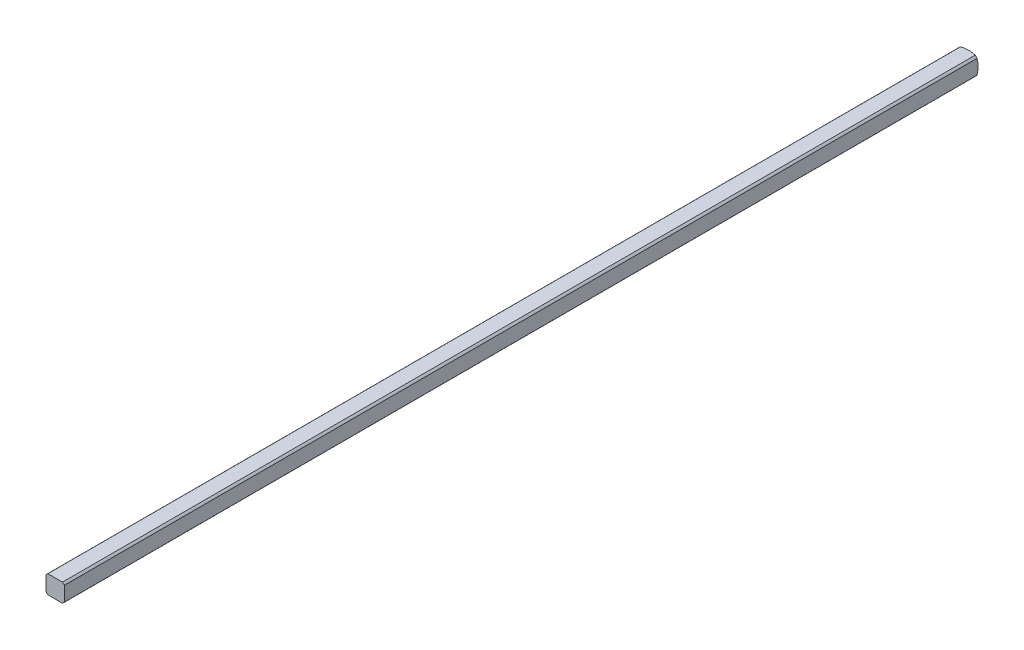
from build123d import *

# Parameters (mm, degrees)
SKETCH1_W           = 3.175
SKETCH1_H           = 3.175
BOSS_EXTRUDE1_DEPTH = 152.4
SKETCH2_OUTSIDE_W   = 35.668
SKETCH2_OUTSIDE_H   = 35.668
SKETCH2_OUTSIDE_R   = 2.032
CUT_EXTRUDE1_DEPTH  = 153.416535561
CUT_EXTRUDE3_DEPTH  = 305.820669872


with BuildPart() as part:
    # Sketch1 → Boss-Extrude1 (new body)
    with BuildSketch(Plane.XY):
        Rectangle(SKETCH1_W, SKETCH1_H)
    extrude(amount=BOSS_EXTRUDE1_DEPTH)

    # Sketch2 outside → Cut-Extrude1 (cut, through all)
    with BuildSketch(Plane(origin=(0, 0, 0), x_dir=(-1, 0, 0), z_dir=(0, 0, -1))):
        Rectangle(SKETCH2_OUTSIDE_W, SKETCH2_OUTSIDE_H)
        Circle(SKETCH2_OUTSIDE_R, mode=Mode.SUBTRACT)
    extrude(amount=-CUT_EXTRUDE1_DEPTH, mode=Mode.SUBTRACT)

    # Sketch3 → Cut-Revolve1 (revolve, cut)
    with BuildSketch(Plane(origin=(0, 0, 0), x_dir=(1, 0, 0), z_dir=(0, 1, 0))):
        with BuildLine():
            Line((-5.053685963, -4.40273269), (-5.053685963, 5.740530545))
            Line((-5.053685963, 5.740530545), (0, 5.740530545))
            Line((0, 5.740530545), (0, 0.160877736))
            ThreePointArc((0, 0.160877736), (-3.404639553, -1.148866368), (-5.053685963, -4.40273269))
        make_face()
    revolve(axis=Axis((0, 0, 152.4), (0, 0, -1)), mode=Mode.SUBTRACT)

    # Mirror1: part across plane


with BuildPart() as part_1:
    add(part.part)
    add(part.part.mirror(Plane(origin=(0, 0, 152.4), x_dir=(1, 0, 0), z_dir=(0, 0, -1))))

    # Sketch4 → Cut-Extrude3 (cut, through all)
    with BuildSketch(Plane(origin=(1.5875, 0, 0), x_dir=(0, 0, -1), z_dir=(1, 0, 0))):
        Polygon((-304.536774642, -1.5875), (-158.486774642, -1.5875), (-158.486774642, 1.5875), (-304.706459955, 1.5875), (-304.8, 1.26832021), (-304.8, -1.26832021), align=None)
    extrude(amount=-CUT_EXTRUDE3_DEPTH, mode=Mode.SUBTRACT)


with BuildPart() as body_2:
    # of the pieces the cut leaves, the one that is kept (cut_extrude3_keep)
    add(part_1.part.solids().sort_by_distance((1.268411507, -1.5875, 0.263225358))[0])


solid = body_2.part
